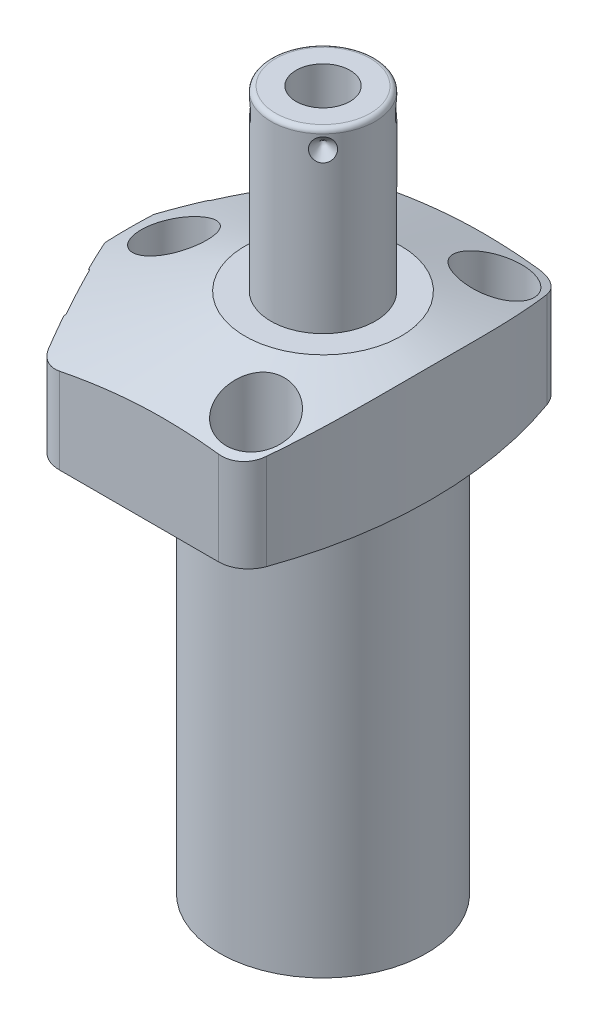
from build123d import *

# Parameters (mm, degrees)
CUT_EXTRUDE1_REACH = 28.975
CUT_EXTRUDE2_REACH = 28.975
S2D0002_OUTSIDE_W  = 122.011
S2D0002_OUTSIDE_H  = 101.742
CUT_EXTRUDE3_DEPTH = 38.0873
FILLET1_R          = 6.35
FILLET2_R          = 6.35
FILLET3_R          = 6.35
SKETCH17_R         = 10.4775
CUT_EXTRUDE4_DEPTH = 0.254
SKETCH18_R         = 5.5626
CUT_EXTRUDE5_DEPTH = 2.667
SKETCH12_R         = 6.4389
EXTRUDE1_DEPTH     = 1.651
EXTRUDE2_START     = -2.667
SKETCH13_R         = 4.8006
EXTRUDE2_DEPTH     = 2.667
CIRPATTERN1_COUNT  = 4
HOLE1_D            = 8.7376
HOLE1_DEPTH        = 26.9748
HOLE1_CBORE_D      = 13.9954
HOLE1_CBORE_DEPTH  = 16.6624


with BuildPart() as part:
    # Sketch1 → Revolve1 (revolve)
    with BuildSketch(Plane(origin=(0, 0, 0), x_dir=(0, -1, 0), z_dir=(0, 0, 1)), mode=Mode.PRIVATE) as revolve1_sk:
        Polygon((0, 44.45), (-26.9748, 44.45), (-26.9748, 0), (84.1502, 0), (84.1502, 22.098), (0, 22.098), align=None)
    revolve(revolve1_sk.sketch.rotate(Axis((0, 32.53105, 0), (0, -1, 0)), 90), axis=Axis((0, 32.53105, 0), (0, -1, 0)))  # turned: the seam where the file's is

    # Sketch2 → Cut-Extrude1 (cut, up to next)
    with BuildSketch(Plane(origin=(0, 0, 0), x_dir=(0, 0, -1), z_dir=(0, -1, 0)), mode=Mode.PRIVATE) as cut_extrude1_sk1:
        with BuildLine():
            Line((34.1122, -28.498426468), (34.1122, 28.498426468))
            ThreePointArc((34.1122, 28.498426468), (44.45, 0), (34.1122, -28.498426468))
        make_face()
    cut_extrude1_tool1 = extrude(cut_extrude1_sk1.sketch, amount=-CUT_EXTRUDE1_REACH, mode=Mode.PRIVATE) & part.part
    add(cut_extrude1_tool1.solids().sort_by_distance((0, 0, -38.291522))[0], mode=Mode.SUBTRACT)
    # Sketch2 → Cut-Extrude1 (cut, up to next)
    with BuildSketch(Plane(origin=(0, 0, 0), x_dir=(0, 0, -1), z_dir=(0, -1, 0)), mode=Mode.PRIVATE) as cut_extrude1_sk2:
        with BuildLine():
            Line((-34.1122, 28.498426468), (-34.1122, -28.498426468))
            ThreePointArc((-34.1122, -28.498426468), (-44.45, 0), (-34.1122, 28.498426468))
        make_face()
    cut_extrude1_tool2 = extrude(cut_extrude1_sk2.sketch, amount=-CUT_EXTRUDE1_REACH, mode=Mode.PRIVATE) & part.part
    add(cut_extrude1_tool2.solids().sort_by_distance((0, 0, 38.291522))[0], mode=Mode.SUBTRACT)

    # Sketch3 → Cut-Extrude2 (cut, up to next)
    with BuildSketch(Plane(origin=(0, 0, 0), x_dir=(-1, 0, 0), z_dir=(0, -1, 0)), mode=Mode.PRIVATE) as cut_extrude2_sk1:
        with BuildLine():
            Line((25.904926114, 34.1122), (44.042704589, 0))
            Line((44.042704589, 0), (25.904926114, -34.1122))
            Line((25.904926114, -34.1122), (28.498426468, -34.1122))
            ThreePointArc((28.498426468, -34.1122), (44.45, 0), (28.498426468, 34.1122))
            Line((28.498426468, 34.1122), (25.904926114, 34.1122))
        make_face()
    cut_extrude2_tool1 = extrude(cut_extrude2_sk1.sketch, amount=-CUT_EXTRUDE2_REACH, mode=Mode.PRIVATE) & part.part
    add(cut_extrude2_tool1.solids().sort_by_distance((-27.201676, 0, -33.4052))[0], mode=Mode.SUBTRACT)

    # S2D0002 outside → Cut-Extrude3 (cut)
    with BuildSketch(Plane(origin=(0, 0, 0), x_dir=(-1, 0, 0), z_dir=(0, -1, 0))):
        with Locations((-0.2035, 0)):
            Rectangle(S2D0002_OUTSIDE_W, S2D0002_OUTSIDE_H)
        with BuildLine():
            Line((41.275, 85.424995881), (41.275, -85.424995881))
            ThreePointArc((41.275, -85.424995881), (-23.0124, 0), (41.275, 85.424995881))
        make_face(mode=Mode.SUBTRACT)
    extrude(amount=-CUT_EXTRUDE3_DEPTH, mode=Mode.SUBTRACT)

    # Fillet1
    fillet1_edges = [part.edges().sort_by_distance(p)[0] for p in [
        (16.207270797, 13.4874, 34.1122),
        (16.207270797, 13.4874, -34.1122),
    ]]
    fillet(fillet1_edges, radius=FILLET1_R)

    # Fillet2
    fillet2_edges = [part.edges().sort_by_distance(p)[0] for p in [
        (-25.904926114, 13.4874, 34.1122),
    ]]
    fillet(fillet2_edges, radius=FILLET2_R)

    # Fillet3
    fillet3_edges = [part.edges().sort_by_distance(p)[0] for p in [
        (-25.904926114, 13.4874, -34.1122),
    ]]
    fillet(fillet3_edges, radius=FILLET3_R)

    # Sketch5 → Cut-Revolve1 (revolve, cut)
    with BuildSketch(Plane.XY, mode=Mode.PRIVATE) as cut_revolve1_sk:
        Polygon((-16.637, 26.9748), (-47.625, 15.696090381), (-47.625, 26.9748), align=None)
    revolve(cut_revolve1_sk.sketch.rotate(Axis((0, 7.66490951, 0), (0, 1, 0)), 90), axis=Axis((0, 7.66490951, 0), (0, 1, 0)), mode=Mode.SUBTRACT)  # turned: the seam where the file's is

    # Sketch6 → Cut-Revolve2 (revolve, cut)
    with BuildSketch(Plane(origin=(-34.111267534, 10.287, -18.137282674), x_dir=(0.469471563, 0, -0.882947593), z_dir=(0, 1, 0))):
        Polygon((0, 0), (6.1849, 0), (5.642306865, -2.5527), (4.9784, -3.216606865), (4.9784, -15.748), (0, -15.748), align=None)
    revolve(axis=Axis((-19.511375907, 10.287, -10.374382594), (-0.882947593, 0, -0.469471563)), mode=Mode.SUBTRACT)

    # Sketch7 → Cut-Revolve3 (revolve, cut)
    with BuildSketch(Plane(origin=(-34.111267534, 10.287, 18.137282674), x_dir=(-0.469471563, 0, -0.882947593), z_dir=(0, 1, 0))):
        Polygon((0, 0), (6.1849, 0), (5.642306865, -2.5527), (4.9784, -3.216606865), (4.9784, -15.748), (0, -15.748), align=None)
    revolve(axis=Axis((-19.511375907, 10.287, 10.374382594), (-0.882947593, 0, 0.469471563)), mode=Mode.SUBTRACT)

    # Sketch8 → Cut-Revolve4 (revolve, cut)
    with BuildSketch(Plane(origin=(-13.4874, 2.667, -26.5938), x_dir=(-1, 0, 0), z_dir=(0, 0, 1)), mode=Mode.PRIVATE) as cut_revolve4_sk:
        Polygon((0, 0), (4.5466, 0), (4.106586662, -2.0701), (3.4544, -2.722286662), (3.4544, -12.573), (0, -12.573), align=None)
    revolve(cut_revolve4_sk.sketch.rotate(Axis((-13.4874, 15.86865, -26.5938), (0, -1, 0)), 270), axis=Axis((-13.4874, 15.86865, -26.5938), (0, -1, 0)), mode=Mode.SUBTRACT)  # turned: the seam where the file's is

    # Sketch9 → Cut-Revolve5 (revolve, cut)
    with BuildSketch(Plane(origin=(-13.4874, 2.667, 26.5938), x_dir=(-1, 0, 0), z_dir=(0, 0, 1)), mode=Mode.PRIVATE) as cut_revolve5_sk:
        Polygon((0, 0), (4.5466, 0), (4.106586662, -2.0701), (3.4544, -2.722286662), (3.4544, -12.573), (0, -12.573), align=None)
    revolve(cut_revolve5_sk.sketch.rotate(Axis((-13.4874, 15.86865, 26.5938), (0, -1, 0)), 270), axis=Axis((-13.4874, 15.86865, 26.5938), (0, -1, 0)), mode=Mode.SUBTRACT)  # turned: the seam where the file's is

    # Sketch17 → Cut-Extrude4 (cut)
    with BuildSketch(Plane(origin=(-34.335536223, 0, 18.256528451), x_dir=(0.469471563, 0, 0.882947593), z_dir=(-0.882947593, 0, 0.469471563))):
        with Locations((0, 10.287)):
            Circle(SKETCH17_R)
    cut_extrude4 = extrude(amount=-CUT_EXTRUDE4_DEPTH, mode=Mode.SUBTRACT)

    # Sketch18 → Cut-Extrude5 (cut)
    with BuildSketch(Plane.XZ):
        with Locations(Location((-13.4874, 26.5938, 0), (0, 0, 270))):  # turned: the seam where the file's is
            Circle(SKETCH18_R)
    cut_extrude5 = extrude(amount=-CUT_EXTRUDE5_DEPTH, mode=Mode.SUBTRACT)

    # Mirror1: Cut-Extrude4, Cut-Extrude5 across plane
    add(cut_extrude4.mirror(Plane.XY), mode=Mode.SUBTRACT)
    add(cut_extrude5.mirror(Plane.XY), mode=Mode.SUBTRACT)

    # Sketch10 → Revolve2 (revolve)
    with BuildSketch(Plane(origin=(0, 0, 0), x_dir=(0, 0, -1), z_dir=(1, 0, 0)), mode=Mode.PRIVATE) as revolve2_sk:
        with BuildLine():
            Line((0, 26.9748), (-11.1125, 26.9748))
            Line((-11.1125, 26.9748), (-11.1125, 63.8302))
            ThreePointArc((-11.1125, 63.8302), (-10.81492049, 64.54862049), (-10.0965, 64.8462))
            Line((-10.0965, 64.8462), (0, 64.8462))
            Line((0, 64.8462), (0, 26.9748))
        make_face()
    revolve(revolve2_sk.sketch.rotate(Axis((0, 14.351681477, 0), (0, 1, 0)), 180), axis=Axis((0, 14.351681477, 0), (0, 1, 0)))  # turned: the seam where the file's is

    # S2D0001 → Cut-Revolve6 (revolve, cut)
    with BuildSketch(Plane(origin=(5.7531, 64.8462, 0), x_dir=(1, 0, 0), z_dir=(0, 0, 1)), mode=Mode.PRIVATE) as cut_revolve6_sk:
        Polygon((0, 0), (0, -17.018), (-5.7531, -20.474811227), (-5.7531, 0), align=None)
    revolve(cut_revolve6_sk.sketch.rotate(Axis((0, 37.109882775, 0), (0, 1, 0)), 90), axis=Axis((0, 37.109882775, 0), (0, 1, 0)), mode=Mode.SUBTRACT)  # turned: the seam where the file's is

    # Sketch12 → Extrude1 (add)
    with BuildSketch(Plane(origin=(-34.111267534, 0, -18.137282674), x_dir=(-0.469471563, 0, 0.882947593), z_dir=(-0.882947593, 0, -0.469471563))):
        with Locations((0, 10.287)):
            Circle(SKETCH12_R)
    extrude(amount=EXTRUDE1_DEPTH)

    # Sketch13 → Extrude2 (add)
    with BuildSketch(Plane.XZ.offset(EXTRUDE2_START)):
        with Locations(Location((-13.4874, -26.5938, 0), (0, 0, 270))):  # turned: the seam where the file's is
            Circle(SKETCH13_R)
    extrude(amount=EXTRUDE2_DEPTH)

    # Sketch14 → Revolve3 (revolve)
    with BuildSketch(Plane(origin=(-13.4874, 0, 26.5938), x_dir=(0, 0, -1), z_dir=(1, 0, 0))):
        with BuildLine():
            Line((5.461, 2.667), (5.461, 0.9398))
            Line((5.461, 0.9398), (5.301559456, 0.9398))
            ThreePointArc((5.301559456, 0.9398), (4.572, -0.4572), (3.842440544, 0.9398))
            Line((3.842440544, 0.9398), (3.175, 0.9398))
            ThreePointArc((3.175, 0.9398), (2.815789755, 0.791010245), (2.667, 0.4318))
            Line((2.667, 0.4318), (2.667, 0.127))
            Line((2.667, 0.127), (1.5875, 0.127))
            Line((1.5875, 0.127), (1.5875, 10.6172))
            Line((1.5875, 10.6172), (3.2512, 10.6172))
            Line((3.2512, 10.6172), (3.2512, 2.667))
            Line((3.2512, 2.667), (5.461, 2.667))
        make_face()
    revolve(axis=Axis((-13.4874, -1.01092, 26.5938), (0, 1, 0)))

    # Sketch15 → Cut-Revolve7 (revolve, cut)
    with BuildSketch(Plane(origin=(-7.857724106, 60.8838, -7.857724106), x_dir=(0, 1, 0), z_dir=(-0.707106781, 0, 0.707106781)), mode=Mode.PRIVATE) as cut_revolve7_sk:
        Polygon((0, 0), (2.413, 0), (0, -2.413), align=None)
    cut_revolve7 = revolve(cut_revolve7_sk.sketch.rotate(Axis((-4.244811433, 60.8838, -4.244811433), (-0.707106781, 0, -0.707106781)), 270), axis=Axis((-4.244811433, 60.8838, -4.244811433), (-0.707106781, 0, -0.707106781)), mode=Mode.SUBTRACT)  # turned: the seam where the file's is

    # CirPattern1: Cut-Revolve7 ×4 about axis
    cirpattern1_axis = Axis((0, 14.351681477, 0), (0, -1, 0))
    for i in range(1, CIRPATTERN1_COUNT):
        add(cut_revolve7.rotate(cirpattern1_axis, i * 360 / CIRPATTERN1_COUNT), mode=Mode.SUBTRACT)

    # Hole1
    with Locations(Plane(origin=(0, 26.9748, 0), x_dir=(-1, 0, 0), z_dir=(0, 1, 0))):
        with Locations((-11.1252, -25.4), (31.75, 0), (-11.1252, 25.4)):
            CounterBoreHole(HOLE1_D / 2, HOLE1_CBORE_D / 2, HOLE1_CBORE_DEPTH, depth=HOLE1_DEPTH)


solid = part.part
